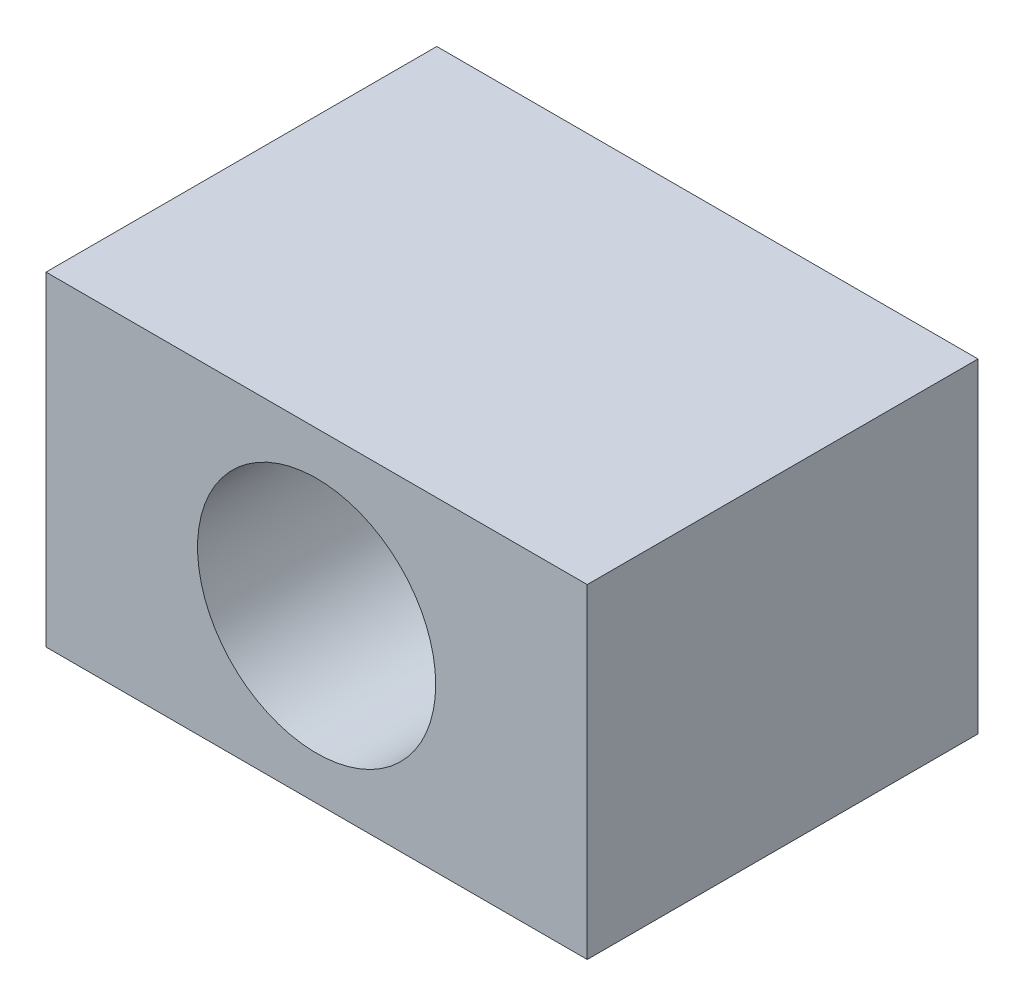
from build123d import *

# Parameters (mm, degrees)
SKETCH1_R           = 11
BOSS_EXTRUDE1_DEPTH = 36.1
SKETCH3_R           = 2.15
CUT_EXTRUDE1_DEPTH  = 17


with BuildPart() as part:
    # Sketch1 → Boss-Extrude1 (new body)
    with BuildSketch(Plane.XY):
        Polygon((-15, 15), (15, 15), (25, 15), (25, 5), (25, -15), (-25, -15), (-25, 5), (-25, 15), align=None)
        Circle(SKETCH1_R, mode=Mode.SUBTRACT)
    extrude(amount=BOSS_EXTRUDE1_DEPTH)

    # Sketch3 → Cut-Extrude1 (cut)
    with BuildSketch(Plane.XZ.offset(15)):
        with Locations((-17.5, 30.05)):
            Circle(SKETCH3_R)
        with Locations((17.5, 30.05)):
            Circle(SKETCH3_R)
        with Locations((17.5, 6.05)):
            Circle(SKETCH3_R)
        with Locations((-17.5, 6.05)):
            Circle(SKETCH3_R)
    extrude(amount=-CUT_EXTRUDE1_DEPTH, mode=Mode.SUBTRACT)


solid = part.part
